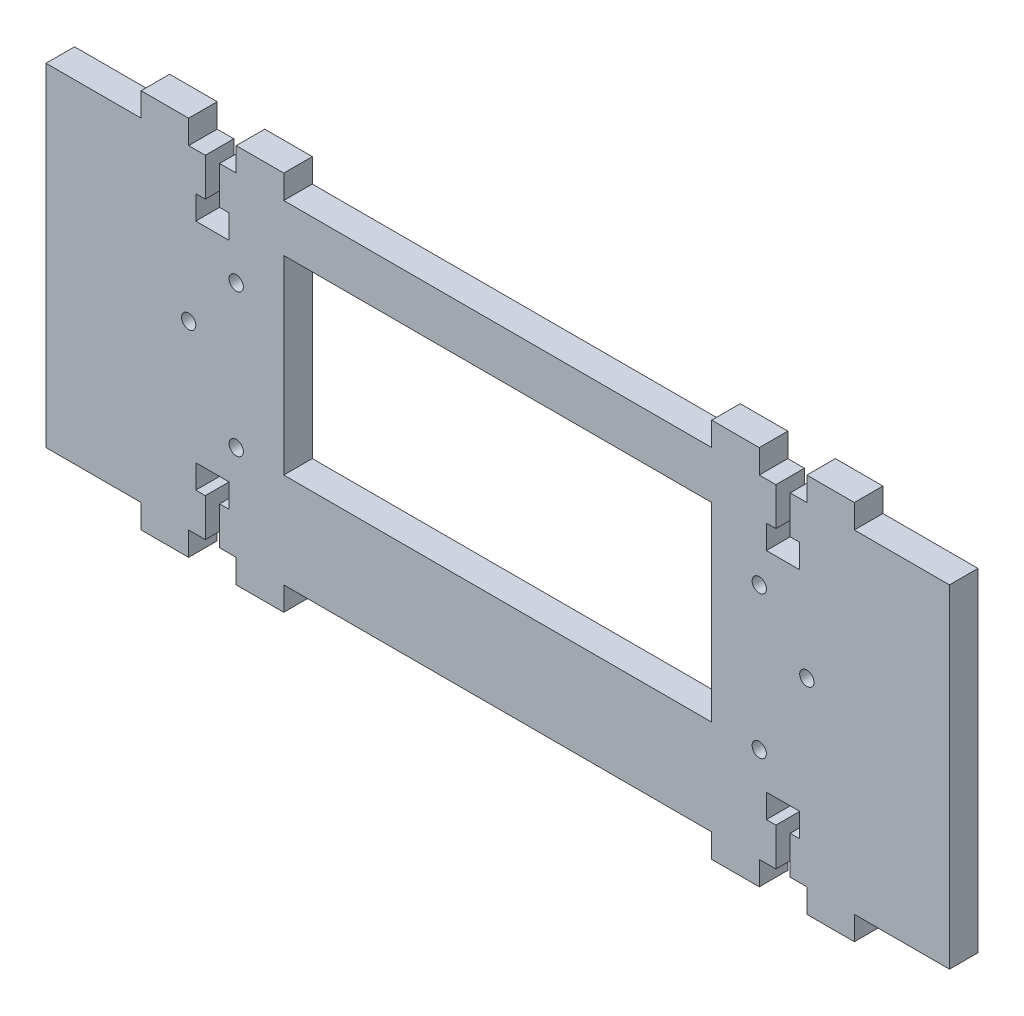
from build123d import *

# Parameters (mm, degrees)
MODEL_R                  = 1.5
MODEL_W                  = 90
MODEL_H                  = 40
RESSALTO_EXTRUS_O1_DEPTH = 6


with BuildPart() as part:
    # Model → Ressalto-extrusão1 (new body)
    with BuildSketch(Plane.XY):
        Polygon((36.5, -62), (36.5, -70), (40, -70), (40, -75), (50, -75), (50, -70), (140, -70), (140, -75), (150, -75), (150, -70), (153.5, -70), (153.5, -62), (151.5, -62), (151.5, -57), (158.5, -57), (158.5, -62), (156.5, -62), (156.5, -70), (160, -70), (160, -75), (170, -75), (170, -70), (190, -70), (190, 0), (170, 0), (170, 5), (160, 5), (160, 0), (156.5, 0), (156.5, -8), (158.5, -8), (158.5, -13), (151.5, -13), (151.5, -8), (153.5, -8), (153.5, 0), (150, 0), (150, 5), (140, 5), (140, 0), (50, 0), (50, 5), (40, 5), (40, 0), (36.5, 0), (36.5, -8), (38.5, -8), (38.5, -13), (31.5, -13), (31.5, -8), (33.5, -8), (33.5, 0), (30, 0), (30, 5), (20, 5), (20, 0), (0, 0), (0, -70), (20, -70), (20, -75), (30, -75), (30, -70), (33.5, -70), (33.5, -62), (31.5, -62), (31.5, -57), (38.5, -57), (38.5, -62), align=None)
        with Locations((30, -32)):
            Circle(MODEL_R, mode=Mode.SUBTRACT)
        with Locations((150, -50)):
            Circle(MODEL_R, mode=Mode.SUBTRACT)
        with Locations((40, -20)):
            Circle(MODEL_R, mode=Mode.SUBTRACT)
        with Locations((150, -20)):
            Circle(MODEL_R, mode=Mode.SUBTRACT)
        with Locations((40, -50)):
            Circle(MODEL_R, mode=Mode.SUBTRACT)
        with Locations((160, -32)):
            Circle(MODEL_R, mode=Mode.SUBTRACT)
        with Locations((95, -30)):
            Rectangle(MODEL_W, MODEL_H, mode=Mode.SUBTRACT)
    extrude(amount=RESSALTO_EXTRUS_O1_DEPTH)


solid = part.part
